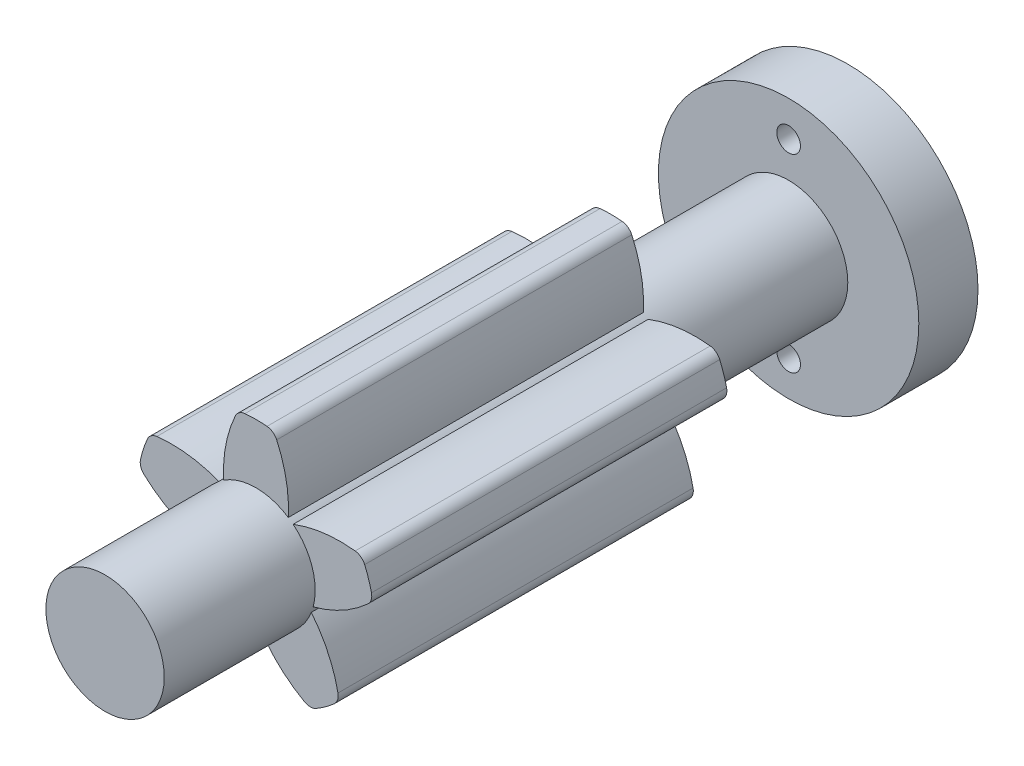
from build123d import *

# Parameters (mm, degrees)
ESQUISSE1_R                        = 11
BOSS_EXTRU_1_DEPTH                 = 5
ESQUISSE2_R                        = 1
ENL_V_MAT_EXTRU_1_DEPTH            = 6
ESQUISSE3_R                        = 5
BOSS_EXTRU_2_DEPTH                 = 57.75
BOSS_EXTRU_3_DEPTH                 = 15
CONG_1_R                           = 1
R_P_TITION_CIRCULAIRE1_COUNT       = 5
CONG_1_OF_R_P_TITION_CIRCULAIRE1_R = 1


with BuildPart() as part:
    # Esquisse1 → Boss.-Extru.1 (new body)
    with BuildSketch(Plane.XY):
        Circle(ESQUISSE1_R)
    extrude(amount=BOSS_EXTRU_1_DEPTH)

    # Esquisse2 → Enlèv. mat.-Extru.1 (cut, through all)
    with BuildSketch(Plane.XY.offset(5)):
        with Locations((0, 8)):
            Circle(ESQUISSE2_R)
        with Locations((0, -8)):
            Circle(ESQUISSE2_R)
    extrude(amount=-ENL_V_MAT_EXTRU_1_DEPTH, mode=Mode.SUBTRACT)

    # Esquisse3 → Boss.-Extru.2 (add)
    with BuildSketch(Plane.XY.offset(5)):
        Circle(ESQUISSE3_R)
    extrude(amount=BOSS_EXTRU_2_DEPTH)

    # Esquisse4 → Boss.-Extru.3 (add, symmetric)
    with BuildSketch(Plane.XY.offset(35)):
        with BuildLine():
            ThreePointArc((-2.731158071, 4.188170912), (-2.5, 7.120566641), (-1.5, 9.886859967))
            ThreePointArc((-1.5, 9.886859967), (0, 10), (1.5, 9.886859967))
            ThreePointArc((1.5, 9.886859967), (2.5, 7.120566641), (2.731158071, 4.188170912))
            ThreePointArc((2.731158071, 4.188170912), (0, -5), (-2.731158071, 4.188170912))
        make_face()
    boss_extru_3 = extrude(amount=BOSS_EXTRU_3_DEPTH, both=True)

    # Congé1
    cong_1_edges = [part.edges().sort_by_distance(p)[0] for p in [
        (1.5, 9.886859967, 35),
        (-1.5, 9.886859967, 35),
    ]]
    fillet(cong_1_edges, radius=CONG_1_R)

    # Répétition circulaire1: Boss.-Extru.3 ×5 about axis
    r_p_tition_circulaire1_axis = Axis((0, 0, 0), (0, 0, 1))
    for i in range(1, R_P_TITION_CIRCULAIRE1_COUNT):
        add(boss_extru_3.rotate(r_p_tition_circulaire1_axis, i * 360 / R_P_TITION_CIRCULAIRE1_COUNT))

    # Congé1 of Répétition circulaire1
    cong_1_of_r_p_tition_circulaire1_edges = [part.edges().sort_by_distance(p)[0] for p in [
        (-8.939437105, 4.481792525, 35),
        (-9.866488089, 1.628622976, 35),
        (-7.024875971, -7.116959856, 35),
        (-4.597824988, -8.880315612, 35),
        (4.597824988, -8.880315612, 35),
        (7.024875971, -7.116959856, 35),
        (9.866488089, 1.628622976, 35),
        (8.939437105, 4.481792525, 35),
    ]]
    fillet(cong_1_of_r_p_tition_circulaire1_edges, radius=CONG_1_OF_R_P_TITION_CIRCULAIRE1_R)


solid = part.part
